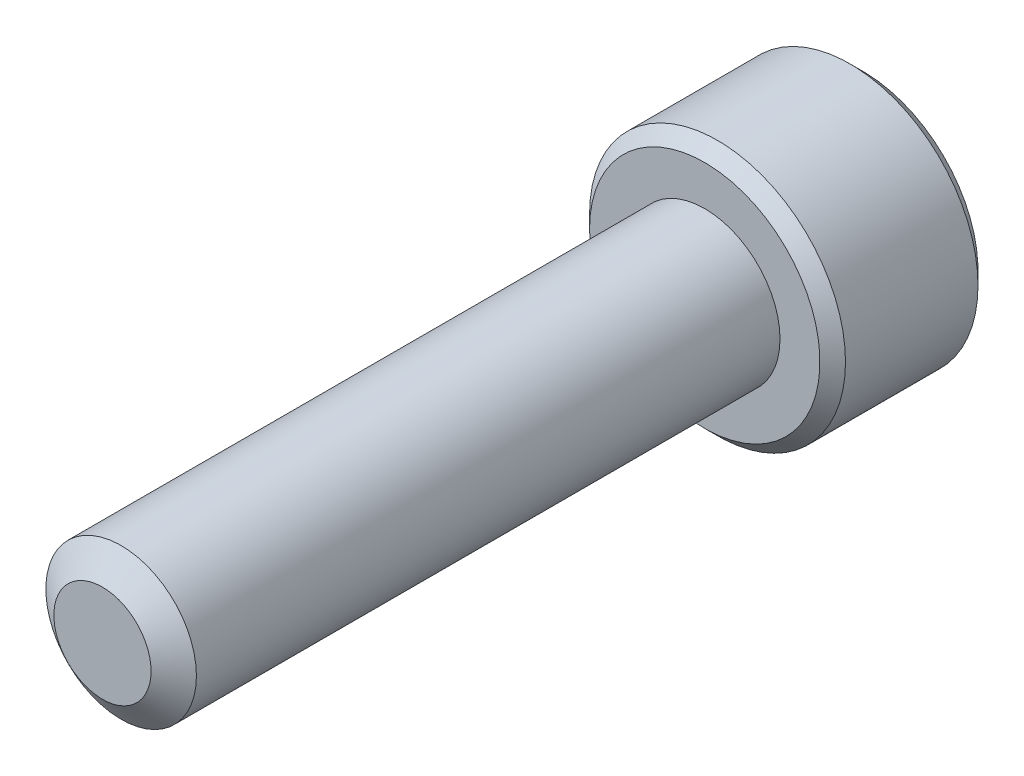
from build123d import *

# Parameters (mm, degrees)
SKETCH1_R          = 2
EXTRUDE1_DEPTH     = 16
SKETCH6_R          = 3.4
EXTRUDE2_DEPTH     = 4.2
CUT_EXTRUDE1_DEPTH = 2.67890625
CHAMFER1_SIZE      = 0.34


with BuildPart() as part:
    # Sketch1 → Extrude1 (new body)
    with BuildSketch(Plane.XY):
        Circle(SKETCH1_R)
    extrude(amount=-EXTRUDE1_DEPTH)

    # Sketch4 → Cut-Revolve1 (revolve, cut)
    with BuildSketch(Plane(origin=(0, 0, 0), x_dir=(0, 0, -1), z_dir=(1, 0, 0))):
        Polygon((0.496211411, 2), (0, 1.291336663), (0, 2), align=None)
    revolve(axis=Axis((0, 0, 0), (0, 0, -1)), mode=Mode.SUBTRACT)

    # Sketch6 → Extrude2 (add)
    with BuildSketch(Plane(origin=(0, 0, -16), x_dir=(-1, 0, 0), z_dir=(0, 0, -1))):
        Circle(SKETCH6_R)
    extrude(amount=EXTRUDE2_DEPTH)

    # Sketch7 → Cut-Extrude1 (cut)
    with BuildSketch(Plane(origin=(0, 0, -20.2), x_dir=(-1, 0, 0), z_dir=(0, 0, -1))):
        Polygon((0, 2.062222993), (-1.7859375, 1.031111496), (-1.7859375, -1.031111496), (0, -2.062222993), (1.7859375, -1.031111496), (1.7859375, 1.031111496), align=None)
    extrude(amount=-CUT_EXTRUDE1_DEPTH, mode=Mode.SUBTRACT)

    # Cut-Extrude2 cone 1 section (through the dimple's axis) → Cut-Extrude2 (revolve, cut)
    with BuildSketch(Plane(origin=(0, 0, -20.2), x_dir=(0, 1, 0), z_dir=(1, 0, 0))):
        Polygon((0, 0), (2.062222993, 0), (0, 2.062222993), align=None)
    revolve(axis=Axis((0, 0, -20.2), (0, 0, 1)), mode=Mode.SUBTRACT)

    # Chamfer1
    chamfer1_edges = [part.edges().sort_by_distance(p)[0] for p in [
        (3.4, 0, -20.2),
        (3.4, 0, -16),
    ]]
    chamfer(chamfer1_edges, length=CHAMFER1_SIZE)


solid = part.part
